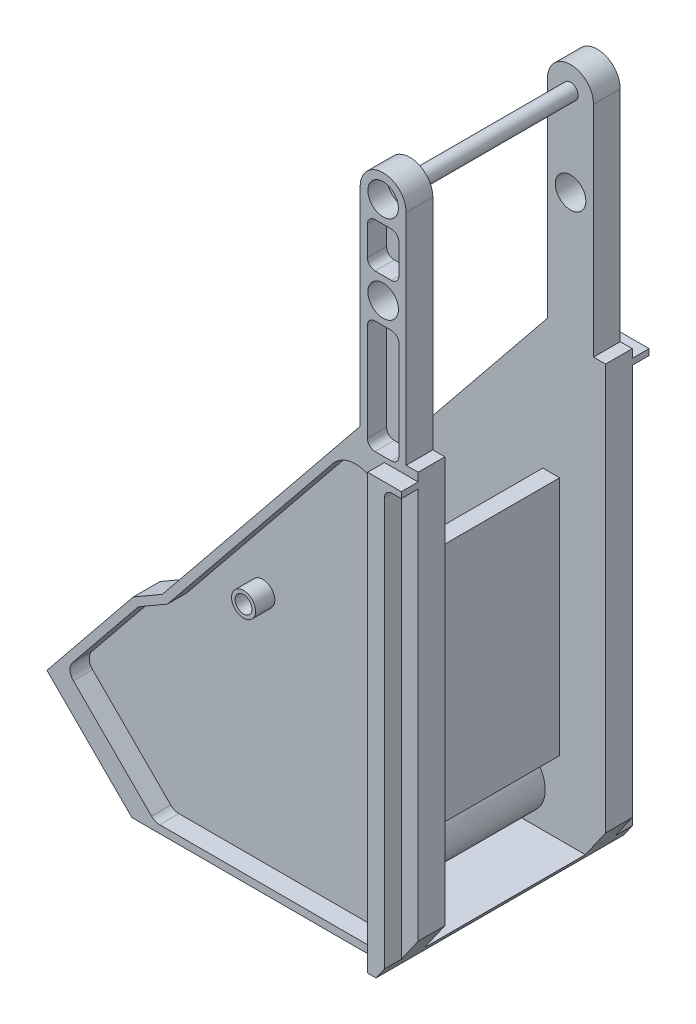
from build123d import *

# Parameters (mm, degrees)
SKETCH1_R           = 3.5
SKETCH1_R_2         = 6.35
BOSS_EXTRUDE1_DEPTH = 89
SKETCH3_R           = 3.5
CUT_EXTRUDE2_DEPTH  = 8
SKETCH4_R           = 5
SKETCH4_R_2         = 3.5
BOSS_EXTRUDE2_DEPTH = 8
BOSS_EXTRUDE3_DEPTH = 7
SKETCH2_W           = 66.8
SKETCH2_H           = 348.711986474
CUT_EXTRUDE1_DEPTH  = 200
SKETCH8_W           = 74.8
SKETCH8_H           = 72.985639166
CUT_EXTRUDE3_DEPTH  = 7
SKETCH7_R           = 12.5
SKETCH7_W           = 109.075865198
SKETCH7_H           = 3
BOSS_EXTRUDE5_DEPTH = 66.8
SKETCH9_R           = 6.35
BOSS_EXTRUDE6_DEPTH = 3
SKETCH10_R          = 3.175
BOSS_EXTRUDE7_DEPTH = 66.8
CUT_EXTRUDE4_DEPTH  = 103


with BuildPart() as part:
    # Sketch1 → Boss-Extrude1 (new body)
    with BuildSketch(Plane.XY):
        with BuildLine():
            Line((48.479853629, 174.820410959), (48.479853629, 88.320410959))
            Line((48.479853629, 88.320410959), (-33.747283956, -13.279329595))
            Line((-33.747283956, -13.279329595), (-45.860496742, -20.29859423))
            Line((-45.860496742, -20.29859423), (-81.750845565, -64.644660941))
            Line((-81.750845565, -64.644660941), (-46.395506505, -100))
            Line((-46.395506505, -100), (72.579853629, -100))
            Line((72.579853629, -100), (72.579853629, 83.820410959))
            Line((72.579853629, 83.820410959), (67.579853629, 83.820410959))
            Line((67.579853629, 83.820410959), (67.579853629, 174.820410959))
            ThreePointArc((67.579853629, 174.820410959), (58.029853629, 184.370410959), (48.479853629, 174.820410959))
        make_face()
        Circle(SKETCH1_R, mode=Mode.SUBTRACT)
        with Locations((58.029853629, 138.320410959)):
            Circle(SKETCH1_R_2, mode=Mode.SUBTRACT)
        with Locations((58.029853629, 174.820410959)):
            Circle(SKETCH1_R_2, mode=Mode.SUBTRACT)
    extrude(amount=-BOSS_EXTRUDE1_DEPTH)

    # Sketch3 → Cut-Extrude2 (cut)
    with BuildSketch(Plane.XY):
        with BuildLine():
            ThreePointArc((-70.750928369, -62.916656075), (-72.139270825, -59.798970454), (-71.085322214, -56.552949701))
            Line((-71.085322214, -56.552949701), (-44.298080789, -23.454670242))
            ThreePointArc((-44.298080789, -23.454670242), (-43.692467175, -22.832236636), (-42.983894314, -22.330125149))
            Line((-42.983894314, -22.330125149), (-31.631604371, -15.751793807))
            Line((-31.631604371, -15.751793807), (37.252005086, 69.360701347))
            ThreePointArc((37.252005086, 69.360701347), (50.583965109, 73.123701006), (58.579853629, 61.811446975))
            Line((58.579853629, 61.811446975), (58.579853629, -92.0375))
            ThreePointArc((58.579853629, -92.0375), (57.184949674, -95.405096045), (53.817353629, -96.8))
            Line((53.817353629, -96.8), (-34.894892353, -96.8))
            ThreePointArc((-34.894892353, -96.8), (-36.7174222, -96.437476274), (-38.262488399, -95.405096045))
            Line((-38.262488399, -95.405096045), (-70.750928369, -62.916656075))
        make_face()
        Circle(SKETCH3_R, mode=Mode.SUBTRACT)
        with BuildLine():
            ThreePointArc((51.479853629, 126.145410959), (52.409789598, 128.390474989), (54.654853629, 129.320410959))
            Line((54.654853629, 129.320410959), (61.404853629, 129.320410959))
            ThreePointArc((61.404853629, 129.320410959), (63.649917659, 128.390474989), (64.579853629, 126.145410959))
            Line((64.579853629, 126.145410959), (64.579853629, 85.495410959))
            ThreePointArc((64.579853629, 85.495410959), (63.649917659, 83.250346929), (61.404853629, 82.320410959))
            Line((61.404853629, 82.320410959), (54.654853629, 82.320410959))
            ThreePointArc((54.654853629, 82.320410959), (52.409789598, 83.250346929), (51.479853629, 85.495410959))
            Line((51.479853629, 85.495410959), (51.479853629, 126.145410959))
        make_face()
        with BuildLine():
            ThreePointArc((51.479853629, 162.645410959), (52.409789598, 164.890474989), (54.654853629, 165.820410959))
            Line((54.654853629, 165.820410959), (61.404853629, 165.820410959))
            ThreePointArc((61.404853629, 165.820410959), (63.649917659, 164.890474989), (64.579853629, 162.645410959))
            Line((64.579853629, 162.645410959), (64.579853629, 150.495410959))
            ThreePointArc((64.579853629, 150.495410959), (63.649917659, 148.250346929), (61.404853629, 147.320410959))
            Line((61.404853629, 147.320410959), (54.654853629, 147.320410959))
            ThreePointArc((54.654853629, 147.320410959), (52.409789598, 148.250346929), (51.479853629, 150.495410959))
            Line((51.479853629, 150.495410959), (51.479853629, 162.645410959))
        make_face()
    cut_extrude2 = extrude(amount=-CUT_EXTRUDE2_DEPTH, mode=Mode.SUBTRACT)

    # Sketch4 → Boss-Extrude2 (add)
    with BuildSketch(Plane.XY.offset(-8)):
        Circle(SKETCH4_R)
        Circle(SKETCH4_R_2, mode=Mode.SUBTRACT)
    extrude(amount=BOSS_EXTRUDE2_DEPTH)

    # Sketch5 → Boss-Extrude3 (add)
    with BuildSketch(Plane.XY):
        with BuildLine():
            Line((58.579853629, 61.811446975), (58.579853629, -92.0375))
            Line((58.579853629, -92.0375), (58.579853629, -100))
            Line((58.579853629, -100), (65.579853629, -100))
            Line((65.579853629, -100), (65.579853629, 74.645410959))
            ThreePointArc((65.579853629, 74.645410959), (66.509789598, 76.890474989), (68.754853629, 77.820410959))
            Line((68.754853629, 77.820410959), (72.579853629, 77.820410959))
            Line((72.579853629, 77.820410959), (72.579853629, 80.320410959))
            Line((72.579853629, 80.320410959), (58.579853629, 80.320410959))
            Line((58.579853629, 80.320410959), (58.579853629, 61.811446975))
        make_face()
    boss_extrude3 = extrude(amount=BOSS_EXTRUDE3_DEPTH)

    # Mirror2: Cut-Extrude2, Boss-Extrude3 across plane
    add(cut_extrude2.mirror(Plane.XY.offset(-44.5)), mode=Mode.SUBTRACT)
    add(boss_extrude3.mirror(Plane.XY.offset(-44.5)))

    # Sketch2 → Cut-Extrude1 (cut)
    with BuildSketch(Plane(origin=(72.579853629, 0, 0), x_dir=(0, 0, -1), z_dir=(1, 0, 0))):
        with Locations((44.5, 44.534818405)):
            Rectangle(SKETCH2_W, SKETCH2_H)
    extrude(amount=-CUT_EXTRUDE1_DEPTH, mode=Mode.SUBTRACT)

    # Sketch8 → Cut-Extrude3 (cut)
    with BuildSketch(Plane(origin=(-73.197753253, -73.197753253, 0), x_dir=(0, 0, 1), z_dir=(-0.707106781, -0.707106781, 0))):
        with Locations((-44.5, -19.729026559)):
            Rectangle(SKETCH8_W, SKETCH8_H)
    extrude(amount=-CUT_EXTRUDE3_DEPTH, mode=Mode.SUBTRACT)

    # Sketch7 → Boss-Extrude5 (add)
    with BuildSketch(Plane.XY.offset(-77.9)):
        Polygon((46.479853629, 31.730850002), (46.479853629, 33.320410959), (6.661618145, -15.878947224), (4.279039025, -13.950668076), (-38.39575734, -66.679589041), (18.545061094, -66.679589041), (46.479853629, -66.679589041), (46.479853629, -65.679589041), (6.815381875, -65.679589041), (-36.299962765, -65.679589041), (4.427255206, -15.357093319), (6.809834326, -17.285372467), align=None)
        Polygon((53.479853629, -66.679589041), (53.479853629, 33.320410959), (46.479853629, 33.320410959), (46.479853629, 31.730850002), (46.479853629, -65.679589041), (46.479853629, -66.679589041), align=None)
        with Locations((35, -82)):
            Circle(SKETCH7_R)
        with Locations((0, -82)):
            Circle(SKETCH7_R)
        with Locations((18.04192103, -98.5)):
            Rectangle(SKETCH7_W, SKETCH7_H)
    extrude(amount=BOSS_EXTRUDE5_DEPTH)

    # Sketch9 → Boss-Extrude6 (add)
    with BuildSketch(Plane(origin=(0, 0, -11.1), x_dir=(-1, 0, 0), z_dir=(0, 0, -1))):
        with Locations((-58.029853629, 174.820410959)):
            Circle(SKETCH9_R)
    boss_extrude6 = extrude(amount=-BOSS_EXTRUDE6_DEPTH)

    # Mirror3: Boss-Extrude6 across plane
    add(boss_extrude6.mirror(Plane.XY.offset(-44.5)))

    # Sketch10 → Boss-Extrude7 (add)
    with BuildSketch(Plane(origin=(0, 0, -11.1), x_dir=(-1, 0, 0), z_dir=(0, 0, -1))):
        with Locations((-58.029853629, 174.820410959)):
            Circle(SKETCH10_R)
    extrude(amount=BOSS_EXTRUDE7_DEPTH)

    # Sketch11 → Cut-Extrude4 (cut)
    with BuildSketch(Plane.XY.offset(7)):
        Polygon((62.079853629, -100), (72.579853629, -85), (72.579853629, -100), align=None)
    extrude(amount=-CUT_EXTRUDE4_DEPTH, mode=Mode.SUBTRACT)


solid = part.part
